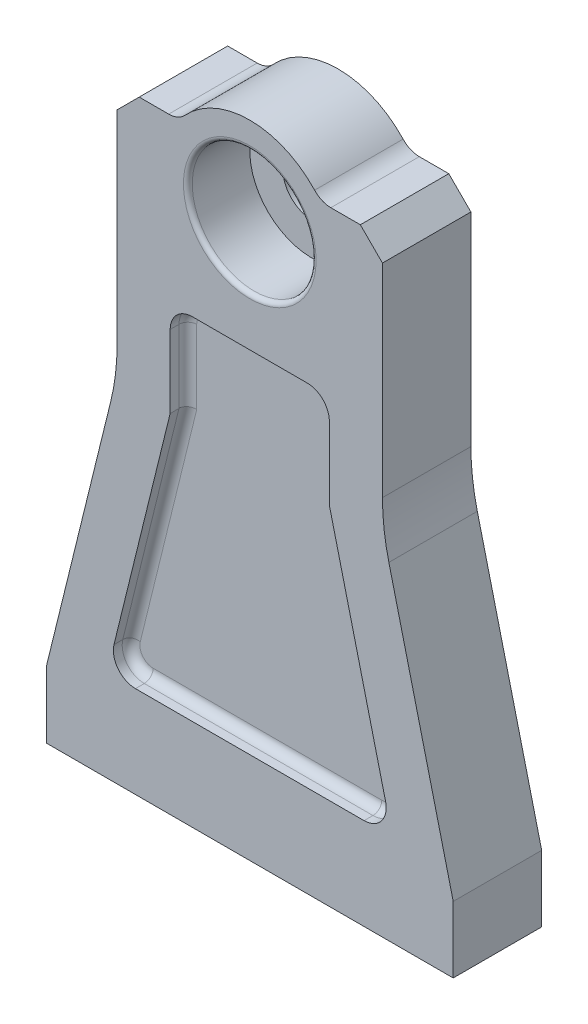
from build123d import *

# Parameters (mm, degrees)
SKETCH2_R                   = 6.5
BOSS_EXTRUDE1_DEPTH         = 10
M10X1_25_TAPPED_HOLE1_D     = 8.8
M10X1_25_TAPPED_HOLE1_DEPTH = 20
M10X1_25_TAPPED_HOLE1_TIP   = 2.643786724
SKETCH8_R                   = 14
CUT_EXTRUDE1_DEPTH          = 14
FILLET1_R                   = 1
CUT_EXTRUDE2_DEPTH          = 4
FILLET2_R                   = 2
FILLET2_OF_MIRROR1_R        = 2
CHAMFER1_SIZE               = 5


with BuildPart() as part:
    # Sketch2 → Boss-Extrude1 (new body, symmetric)
    with BuildSketch(Plane.XY):
        with BuildLine():
            Line((-18.33030278, 12), (-30, 12))
            Line((-30, 12), (-30, -38.93665036))
            ThreePointArc((-30, -38.93665036), (-30.363636327, -44.955902916), (-31.449256053, -50.887602716))
            Line((-31.449256053, -50.887602716), (-46, -110))
            Line((-46, -110), (-46, -125))
            Line((-46, -125), (46, -125))
            Line((46, -125), (46, -110))
            Line((46, -110), (31.449256053, -50.887602716))
            ThreePointArc((31.449256053, -50.887602716), (30.363636327, -44.955902916), (30, -38.93665036))
            Line((30, -38.93665036), (30, 12))
            Line((30, 12), (18.33030278, 12))
            ThreePointArc((18.33030278, 12), (16.33030278, 12.417424305), (14.664242224, 13.6))
            ThreePointArc((14.664242224, 13.6), (0, 20), (-14.664242224, 13.6))
            ThreePointArc((-14.664242224, 13.6), (-16.33030278, 12.417424305), (-18.33030278, 12))
        make_face()
        Circle(SKETCH2_R, mode=Mode.SUBTRACT)
    extrude(amount=BOSS_EXTRUDE1_DEPTH, both=True)

    # M10x1.25 Tapped Hole1
    with Locations(Plane(origin=(0, -125, 0), x_dir=(-1, 0, 0), z_dir=(0, -1, 0))):
        with Locations((30, 0), (-30, 0)):
            Hole(M10X1_25_TAPPED_HOLE1_D / 2, depth=M10X1_25_TAPPED_HOLE1_DEPTH)
            with Locations((0, 0, -(M10X1_25_TAPPED_HOLE1_DEPTH + M10X1_25_TAPPED_HOLE1_TIP / 2))):  # 118° drill point
                Cone(0, M10X1_25_TAPPED_HOLE1_D / 2, M10X1_25_TAPPED_HOLE1_TIP, mode=Mode.SUBTRACT)

    # Sketch8 → Cut-Extrude1 (cut)
    with BuildSketch(Plane.XY.offset(10)):
        Circle(SKETCH8_R)
    extrude(amount=-CUT_EXTRUDE1_DEPTH, mode=Mode.SUBTRACT)

    # Fillet1
    fillet1_edges = [part.edges().sort_by_distance(p)[0] for p in [
        (-14, 0, 10),
    ]]
    fillet(fillet1_edges, radius=FILLET1_R)

    # Sketch9 → Cut-Extrude2 (cut)
    with BuildSketch(Plane.XY.offset(10)):
        with BuildLine():
            Line((-30.703970126, -98.065082549), (-18, -46.455203914))
            Line((-18, -46.455203914), (-18, -30))
            ThreePointArc((-18, -30), (-16.535533906, -26.464466094), (-13, -25))
            Line((-13, -25), (13, -25))
            ThreePointArc((13, -25), (16.535533906, -26.464466094), (18, -30))
            Line((18, -30), (18, -46.455203914))
            Line((18, -46.455203914), (30.703970126, -98.065082549))
            ThreePointArc((30.703970126, -98.065082549), (29.784342096, -102.344373289), (25.848895731, -104.260177784))
            Line((25.848895731, -104.260177784), (-25.848895731, -104.260177784))
            ThreePointArc((-25.848895731, -104.260177784), (-29.784342096, -102.344373289), (-30.703970126, -98.065082549))
        make_face()
    cut_extrude2 = extrude(amount=-CUT_EXTRUDE2_DEPTH, mode=Mode.SUBTRACT)

    # Fillet2
    fillet2_edges = [part.edges().sort_by_distance(p)[0] for p in [
        (-18, -38.227601957, 6),
        (-16.535533906, -26.464466094, 6),
        (0, -25, 6),
        (16.535533906, -26.464466094, 6),
        (18, -38.227601957, 6),
        (24.351985063, -72.260143231, 6),
        (29.784342096, -102.344373289, 6),
        (0, -104.260177784, 6),
        (-29.784342096, -102.344373289, 6),
        (-24.351985063, -72.260143231, 6),
    ]]
    fillet(fillet2_edges, radius=FILLET2_R)

    # Mirror1: Cut-Extrude2 across plane
    add(cut_extrude2.mirror(Plane.XY), mode=Mode.SUBTRACT)

    # Fillet2 of Mirror1
    fillet2_of_mirror1_edges = [part.edges().sort_by_distance(p)[0] for p in [
        (-18, -38.227601957, -6),
        (-16.535533906, -26.464466094, -6),
        (0, -25, -6),
        (16.535533906, -26.464466094, -6),
        (18, -38.227601957, -6),
        (24.351985063, -72.260143231, -6),
        (29.784342096, -102.344373289, -6),
        (0, -104.260177784, -6),
        (-29.784342096, -102.344373289, -6),
        (-24.351985063, -72.260143231, -6),
    ]]
    fillet(fillet2_of_mirror1_edges, radius=FILLET2_OF_MIRROR1_R)

    # Chamfer1
    chamfer1_edges = [part.edges().sort_by_distance(p)[0] for p in [
        (30, 12, 0),
        (-30, 12, 0),
    ]]
    chamfer(chamfer1_edges, length=CHAMFER1_SIZE)


solid = part.part
